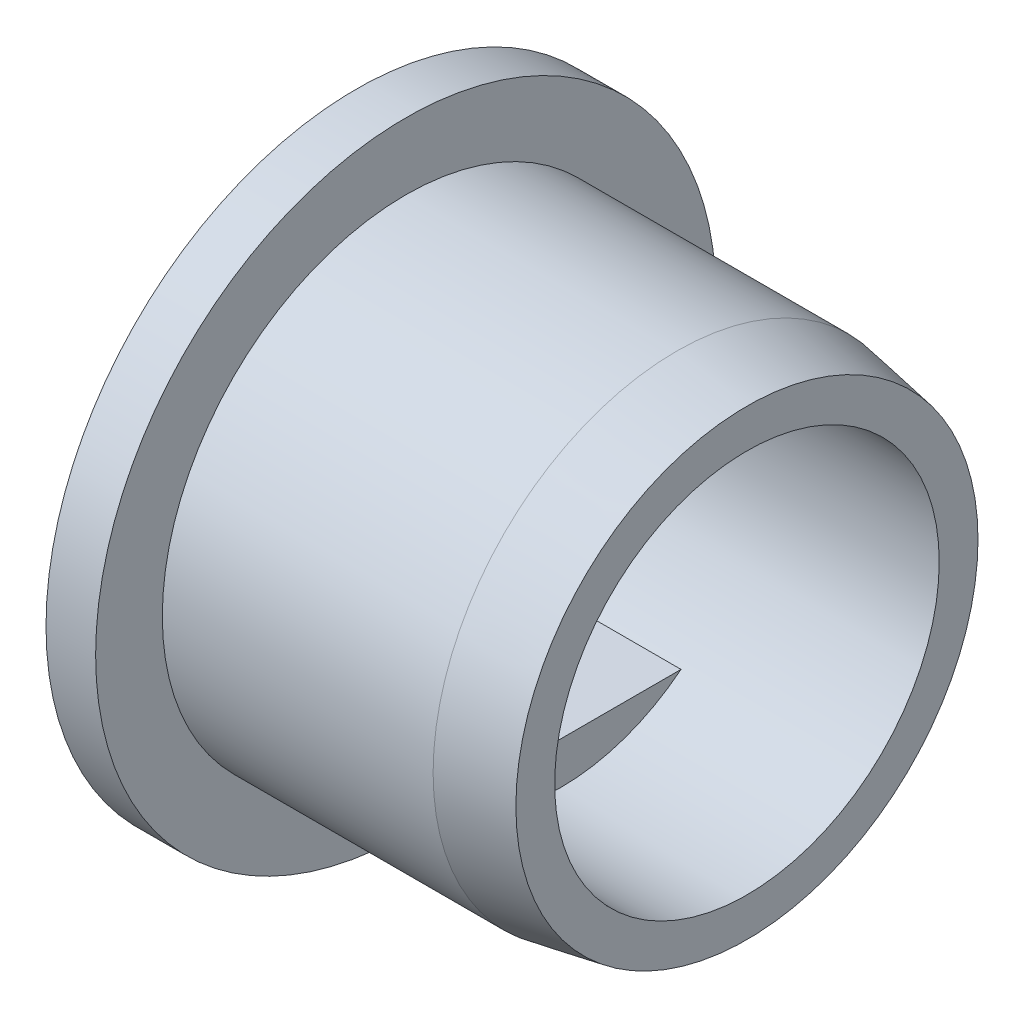
from build123d import *

# Parameters (mm, degrees)
SKETCH1_R                = 20
BOSS_EXTRUDE1_DEPTH      = 150
SKETCH1_3_R              = 8.5
BOSS_EXTRUDE2_DEPTH      = 0.8
BOSS_EXTRUDE3_START      = -0.8
SKETCH1_4_R              = 3.925
BOSS_EXTRUDE3_DEPTH      = 8.5
BOSS_EXTRUDE4_START      = 150
SKETCH1_9_R              = 8.5
SKETCH1_9_R_2            = 3.925
BOSS_EXTRUDE4_DEPTH      = 0.8
BOSS_EXTRUDE5_START      = 150.8
SKETCH1_10_R             = 3.925
BOSS_EXTRUDE5_DEPTH      = 5.5
SKETCH2_W                = 1
SKETCH2_H                = 2
SKETCH3_R                = 22.5
BOSS_EXTRUDE6_DEPTH      = 10
CUT_EXTRUDE1_START       = 156.3
CUT_EXTRUDE1_DEPTH       = 20
CUT_EXTRUDE2_START       = 156.3
CUT_EXTRUDE2_DEPTH       = 3
CUT_EXTRUDE3_DEPTH       = 10
FILLET1_R                = 0.5
FILLET2_R                = 1
CIRPATTERN1_COUNT        = 16
FILLET1_OF_CIRPATTERN1_R = 0.5
FILLET2_OF_CIRPATTERN1_R = 1
SKETCH4_OUTSIDE_W        = 82.236
SKETCH4_OUTSIDE_H        = 82.236
CUT_EXTRUDE4_DEPTH       = 10
CHAMFER1_SIZE            = 0.2
CHAMFER1_SIZE2           = 1.134256364
CHAMFER2_SIZE            = 0.2
CHAMFER2_SIZE2           = 1.134256364
SKETCH6_R                = 38.669160418
CUT_EXTRUDE5_DEPTH       = 160.3
SKETCH7_OUTSIDE_W        = 23.97
SKETCH7_OUTSIDE_H        = 23.97
SKETCH7_OUTSIDE_R        = 7
CUT_EXTRUDE6_DEPTH       = 10
SKETCH8_OUTSIDE_W        = 20.156
SKETCH8_OUTSIDE_H        = 20.156
SKETCH8_OUTSIDE_R        = 5
CUT_EXTRUDE7_DEPTH       = 10


with BuildPart() as part:
    # Sketch1 → Boss-Extrude1 (new body)
    with BuildSketch(Plane(origin=(0, 0, 0), x_dir=(0, 0, -1), z_dir=(1, 0, 0))):
        Circle(SKETCH1_R)
    extrude(amount=BOSS_EXTRUDE1_DEPTH)

    # Sketch1_3 → Boss-Extrude2 (add)
    with BuildSketch(Plane(origin=(0, 0, 0), x_dir=(0, 0, -1), z_dir=(1, 0, 0))):
        Circle(SKETCH1_3_R)
    extrude(amount=-BOSS_EXTRUDE2_DEPTH)

    # Sketch1_4 → Boss-Extrude3 (add)
    with BuildSketch(Plane(origin=(0, 0, 0), x_dir=(0, 0, -1), z_dir=(1, 0, 0)).offset(BOSS_EXTRUDE3_START)):
        Circle(SKETCH1_4_R)
    extrude(amount=-BOSS_EXTRUDE3_DEPTH)

    # Sketch1_9 → Boss-Extrude4 (add)
    with BuildSketch(Plane(origin=(0, 0, 0), x_dir=(0, 0, -1), z_dir=(1, 0, 0)).offset(BOSS_EXTRUDE4_START)):
        Circle(SKETCH1_9_R)
        Circle(SKETCH1_9_R_2, mode=Mode.SUBTRACT)
        Circle(SKETCH1_9_R_2)
        with BuildLine():
            ThreePointArc((1.937420966, -2.42), (0, 3.1), (-1.937420966, -2.42))
            ThreePointArc((-1.937420966, -2.42), (0, -3.1), (1.937420966, -2.42))
        make_face(mode=Mode.SUBTRACT)
        with BuildLine():
            Line((-1.937420966, -2.42), (1.937420966, -2.42))
            ThreePointArc((1.937420966, -2.42), (0, 3.1), (-1.937420966, -2.42))
        make_face()
        with BuildLine():
            ThreePointArc((1.937420966, -2.42), (0, -3.1), (-1.937420966, -2.42))
            Line((-1.937420966, -2.42), (1.937420966, -2.42))
        make_face()
    extrude(amount=BOSS_EXTRUDE4_DEPTH)

    # Sketch1_10 → Boss-Extrude5 (add)
    with BuildSketch(Plane(origin=(0, 0, 0), x_dir=(0, 0, -1), z_dir=(1, 0, 0)).offset(BOSS_EXTRUDE5_START)):
        Circle(SKETCH1_10_R)
    extrude(amount=BOSS_EXTRUDE5_DEPTH)

    # Sketch2 → Cut-Revolve1 (revolve, cut)
    with BuildSketch(Plane.XY, mode=Mode.PRIVATE) as cut_revolve1_sk:
        Polygon((27, 20), (1, 20), (1, 18), (14, 18.6), (27, 18), align=None)
        Polygon((27, 18), (27, 20), (28, 20), (29, 20), (29, 18), align=None)
        Polygon((29, 20), (29, 18), (42, 18.6), (55, 18), (55, 20), align=None)
        Polygon((55, 18), (55, 20), (56, 20), (57, 20), (57, 18), align=None)
        Polygon((57, 20), (57, 18), (70, 18.6), (83, 18), (83, 20), align=None)
        Polygon((83, 18), (83, 20), (84, 20), (85, 20), (85, 18), align=None)
        Polygon((85, 20), (85, 18), (98, 18.6), (111, 18), (111, 20), align=None)
        Polygon((111, 18), (111, 20), (112, 20), (113, 20), (113, 18), align=None)
        Polygon((113, 20), (113, 18), (126, 18.6), (139, 18), (139, 19.9), (139, 20), align=None)
        Polygon((140, 20), (139, 20), (139, 19.9), (150, 19.9), (150, 20), align=None)
        with Locations((0.5, 19)):
            Rectangle(SKETCH2_W, SKETCH2_H)
    revolve(cut_revolve1_sk.sketch.rotate(Axis((0, 0, 0), (1, 0, 0)), 90), axis=Axis((0, 0, 0), (1, 0, 0)), mode=Mode.SUBTRACT)  # turned: the seam where the file's is

    # Sketch3 → Boss-Extrude6 (add)
    with BuildSketch(Plane(origin=(150, 0, 0), x_dir=(0, 0, -1), z_dir=(1, 0, 0))):
        Circle(SKETCH3_R)
    extrude(amount=-BOSS_EXTRUDE6_DEPTH)

    # Sketch1_5 → Cut-Extrude1 (cut)
    with BuildSketch(Plane(origin=(0, 0, 0), x_dir=(0, 0, -1), z_dir=(1, 0, 0)).offset(CUT_EXTRUDE1_START)):
        with BuildLine():
            Line((-1.937420966, -2.42), (1.937420966, -2.42))
            ThreePointArc((1.937420966, -2.42), (0, 3.1), (-1.937420966, -2.42))
        make_face()
    extrude(amount=-CUT_EXTRUDE1_DEPTH, mode=Mode.SUBTRACT)

    # Sketch1_8 → Cut-Extrude2 (cut)
    with BuildSketch(Plane(origin=(0, 0, 0), x_dir=(0, 0, -1), z_dir=(1, 0, 0)).offset(CUT_EXTRUDE2_START)):
        with BuildLine():
            ThreePointArc((1.937420966, -2.42), (0, -3.1), (-1.937420966, -2.42))
            Line((-1.937420966, -2.42), (1.937420966, -2.42))
        make_face()
    extrude(amount=-CUT_EXTRUDE2_DEPTH, mode=Mode.SUBTRACT)

    # Sketch3_3 → Cut-Extrude3 (cut)
    with BuildSketch(Plane(origin=(150, 0, 0), x_dir=(0, 0, -1), z_dir=(1, 0, 0))):
        with BuildLine():
            Line((18.793852416, 0), (16.875, 0))
            ThreePointArc((16.875, 0), (16.816528534, -1.403564417), (16.641519339, -2.797402201))
            Line((16.641519339, -2.797402201), (18.533822722, -3.11549417))
            add(Edge.make_bspline(
                [(18.533822722, -3.11549417), (18.540143259, -3.116650367), (18.557818877, -3.120174741), (18.59102423, -3.127948355), (18.644868838, -3.14220254), (18.712949139, -3.162664487), (18.800284389, -3.191738795), (18.902266481, -3.229352045), (19.01333304, -3.274191401), (19.133012214, -3.326732031), (19.251334581, -3.382453012), (19.368317547, -3.441093179), (19.483872699, -3.502252085), (19.622639053, -3.579554465), (19.787320314, -3.676709438), (19.977176405, -3.796702318), (20.189293185, -3.940335966), (20.401861332, -4.094683446), (20.60799726, -4.25307101), (20.812611431, -4.420472139), (21.00798126, -4.587659246), (21.20695704, -4.768722867), (21.388624735, -4.939634627), (21.58456819, -5.136136858), (21.702177554, -5.256735347), (21.796059885, -5.357369907), (21.840902155, -5.406014525)],
                knots=[0, 0, 0, 0, 0, 0.005376749, 0.015083688, 0.02853182, 0.04661014, 0.064854849, 0.092110525, 0.119476176, 0.146842496, 0.174208854, 0.201574956, 0.228941013, 0.256307345, 0.307035032, 0.361767352, 0.416499661, 0.471231937, 0.525964282, 0.580696616, 0.635428982, 0.690161387, 0.744893688, 0.799626082, 0.851029126, 0.851029126, 0.851029126, 0.851029126, 0.851029126], degree=4))
            ThreePointArc((21.840902155, -5.406014525), (22.334617732, -2.723022357), (22.5, 0))
            ThreePointArc((22.5, 0), (22.483713995, 0.855923463), (22.434879558, 1.710607852))
            add(Edge.make_bspline(
                [(18.793852416, 0), (18.800277167, 9.2432e-05), (18.81829247, 0.000637921), (18.852327044, 0.002799463), (18.907789609, 0.007930502), (18.978319976, 0.016823532), (19.06926657, 0.031017834), (19.176072873, 0.051204897), (19.293035835, 0.077012138), (19.419768906, 0.108986367), (19.545691155, 0.144321865), (19.670776454, 0.182758195), (19.79487123, 0.223915106), (19.944532197, 0.277144366), (20.123040519, 0.345655574), (20.33016124, 0.432515425), (20.563153629, 0.538998755), (20.798367194, 0.655972857), (21.027907269, 0.777997426), (21.257440837, 0.909163115), (21.477822489, 1.041650195), (21.704060536, 1.187224031), (21.911547079, 1.32565566), (22.137354045, 1.486957173), (22.27332803, 1.586390737), (22.382593806, 1.670069867), (22.434879558, 1.710607852)],
                knots=[0, 0, 0, 0, 0, 0.005376749, 0.015083688, 0.02853182, 0.04661014, 0.064854849, 0.092110525, 0.119476176, 0.146842496, 0.174208854, 0.201574956, 0.228941013, 0.256307345, 0.307035032, 0.361767352, 0.416499661, 0.471231937, 0.525964282, 0.580696616, 0.635428982, 0.690161387, 0.744893688, 0.799626082, 0.851029126, 0.851029126, 0.851029126, 0.851029126, 0.851029126], degree=4))
        make_face()
        with BuildLine():
            Line((18.793852416, 0), (16.875, 0))
            ThreePointArc((16.875, 0), (16.816528534, -1.403564417), (16.641519339, -2.797402201))
            Line((16.641519339, -2.797402201), (18.533822722, -3.11549417))
            add(Edge.make_bspline(
                [(18.533822722, -3.11549417), (18.540143259, -3.116650367), (18.557818877, -3.120174741), (18.59102423, -3.127948355), (18.644868838, -3.14220254), (18.712949139, -3.162664487), (18.800284389, -3.191738795), (18.902266481, -3.229352045), (19.01333304, -3.274191401), (19.133012214, -3.326732031), (19.251334581, -3.382453012), (19.368317547, -3.441093179), (19.483872699, -3.502252085), (19.622639053, -3.579554465), (19.787320314, -3.676709438), (19.977176405, -3.796702318), (20.189293185, -3.940335966), (20.401861332, -4.094683446), (20.60799726, -4.25307101), (20.812611431, -4.420472139), (21.00798126, -4.587659246), (21.20695704, -4.768722867), (21.388624735, -4.939634627), (21.58456819, -5.136136858), (21.702177554, -5.256735347), (21.796059885, -5.357369907), (21.840902155, -5.406014525)],
                knots=[0, 0, 0, 0, 0, 0.005376749, 0.015083688, 0.02853182, 0.04661014, 0.064854849, 0.092110525, 0.119476176, 0.146842496, 0.174208854, 0.201574956, 0.228941013, 0.256307345, 0.307035032, 0.361767352, 0.416499661, 0.471231937, 0.525964282, 0.580696616, 0.635428982, 0.690161387, 0.744893688, 0.799626082, 0.851029126, 0.851029126, 0.851029126, 0.851029126, 0.851029126], degree=4))
            ThreePointArc((21.840902155, -5.406014525), (22.334617732, -2.723022357), (22.5, 0))
            ThreePointArc((22.5, 0), (22.483713995, 0.855923463), (22.434879558, 1.710607852))
            add(Edge.make_bspline(
                [(18.793852416, 0), (18.800277167, 9.2432e-05), (18.81829247, 0.000637921), (18.852327044, 0.002799463), (18.907789609, 0.007930502), (18.978319976, 0.016823532), (19.06926657, 0.031017834), (19.176072873, 0.051204897), (19.293035835, 0.077012138), (19.419768906, 0.108986367), (19.545691155, 0.144321865), (19.670776454, 0.182758195), (19.79487123, 0.223915106), (19.944532197, 0.277144366), (20.123040519, 0.345655574), (20.33016124, 0.432515425), (20.563153629, 0.538998755), (20.798367194, 0.655972857), (21.027907269, 0.777997426), (21.257440837, 0.909163115), (21.477822489, 1.041650195), (21.704060536, 1.187224031), (21.911547079, 1.32565566), (22.137354045, 1.486957173), (22.27332803, 1.586390737), (22.382593806, 1.670069867), (22.434879558, 1.710607852)],
                knots=[0, 0, 0, 0, 0, 0.005376749, 0.015083688, 0.02853182, 0.04661014, 0.064854849, 0.092110525, 0.119476176, 0.146842496, 0.174208854, 0.201574956, 0.228941013, 0.256307345, 0.307035032, 0.361767352, 0.416499661, 0.471231937, 0.525964282, 0.580696616, 0.635428982, 0.690161387, 0.744893688, 0.799626082, 0.851029126, 0.851029126, 0.851029126, 0.851029126, 0.851029126], degree=4))
        make_face()
    cut_extrude3 = extrude(amount=-CUT_EXTRUDE3_DEPTH, mode=Mode.SUBTRACT)

    # Fillet1
    fillet1_edges = [part.edges().sort_by_distance(p)[0] for p in [
        (145, -2.797402201, -16.641519339),
        (145, 0, -16.875),
    ]]
    fillet(fillet1_edges, radius=FILLET1_R)

    # Fillet2
    fillet2_edges = [part.edges().sort_by_distance(p)[0] for p in [
        (145, 1.710607852, -22.434879558),
        (145, -5.406014525, -21.840902155),
    ]]
    fillet(fillet2_edges, radius=FILLET2_R)

    # CirPattern1: Cut-Extrude3 ×16 about axis
    cirpattern1_axis = Axis((126, 0, 0), (-1, 0, 0))
    for i in range(1, CIRPATTERN1_COUNT):
        add(cut_extrude3.rotate(cirpattern1_axis, i * 360 / CIRPATTERN1_COUNT), mode=Mode.SUBTRACT)

    # Fillet1 of CirPattern1
    fillet1_of_cirpattern1_edges = [part.edges().sort_by_distance(p)[0] for p in [
        (145, -8.952896379, -14.304239631),
        (145, -6.457782921, -15.590467111),
        (145, -13.74539324, -9.789269108),
        (145, -11.932426933, -11.932426933),
        (145, -16.445278584, -3.783971103),
        (145, -15.590467111, -6.457782921),
        (145, -16.641519339, 2.797402201),
        (145, -16.875, 0),
        (145, -14.304239631, 8.952896379),
        (145, -15.590467111, 6.457782921),
        (145, -9.789269108, 13.74539324),
        (145, -11.932426933, 11.932426933),
        (145, -3.783971103, 16.445278584),
        (145, -6.457782921, 15.590467111),
        (145, 2.797402201, 16.641519339),
        (145, 0, 16.875),
        (145, 8.952896379, 14.304239631),
        (145, 6.457782921, 15.590467111),
        (145, 13.74539324, 9.789269108),
        (145, 11.932426933, 11.932426933),
        (145, 16.445278584, 3.783971103),
        (145, 15.590467111, 6.457782921),
        (145, 16.641519339, -2.797402201),
        (145, 16.875, 0),
        (145, 14.304239631, -8.952896379),
        (145, 15.590467111, -6.457782921),
        (145, 9.789269108, -13.74539324),
        (145, 11.932426933, -11.932426933),
        (145, 3.783971103, -16.445278584),
        (145, 6.457782921, -15.590467111),
    ]]
    fillet(fillet1_of_cirpattern1_edges, radius=FILLET1_OF_CIRPATTERN1_R)

    # Fillet2 of CirPattern1
    fillet2_of_cirpattern1_edges = [part.edges().sort_by_distance(p)[0] for p in [
        (145, -7.005061131, -21.381747322),
        (145, -13.352657575, -18.109570279),
        (145, -14.654273058, -17.073437883),
        (145, -19.266479551, -11.621220491),
        (145, -20.072504754, -10.165852297),
        (145, -22.247154667, -3.36364523),
        (145, -22.434879558, -1.710607852),
        (145, -21.840902155, 5.406014525),
        (145, -21.381747322, 7.005061131),
        (145, -18.109570279, 13.352657575),
        (145, -17.073437883, 14.654273058),
        (145, -11.621220491, 19.266479551),
        (145, -10.165852297, 20.072504754),
        (145, -3.36364523, 22.247154667),
        (145, -1.710607852, 22.434879558),
        (145, 5.406014525, 21.840902155),
        (145, 7.005061131, 21.381747322),
        (145, 13.352657575, 18.109570279),
        (145, 14.654273058, 17.073437883),
        (145, 19.266479551, 11.621220491),
        (145, 20.072504754, 10.165852297),
        (145, 22.247154667, 3.36364523),
        (145, 22.434879558, 1.710607852),
        (145, 21.840902155, -5.406014525),
        (145, 21.381747322, -7.005061131),
        (145, 18.109570279, -13.352657575),
        (145, 17.073437883, -14.654273058),
        (145, 11.621220491, -19.266479551),
        (145, 10.165852297, -20.072504754),
        (145, 3.36364523, -22.247154667),
    ]]
    fillet(fillet2_of_cirpattern1_edges, radius=FILLET2_OF_CIRPATTERN1_R)

    # Sketch4 outside → Cut-Extrude4 (cut)
    with BuildSketch(Plane(origin=(150, 0, 0), x_dir=(0, 0, -1), z_dir=(1, 0, 0))):
        Rectangle(SKETCH4_OUTSIDE_W, SKETCH4_OUTSIDE_H)
        with BuildLine():
            Line((16.084027229, -6.553982996), (17.400825548, -7.099418718))
            add(Edge.make_bspline(
                [(17.400825548, -7.099418718), (17.468205114, -7.126079363), (17.53735939, -7.143460734), (17.675930951, -7.176848305), (17.745707701, -7.190975003), (17.956070336, -7.22795715), (18.097788211, -7.245382593), (18.52533898, -7.282064664), (18.810706139, -7.285520422), (19.667508071, -7.251758438), (20.232380272, -7.171231176), (20.790500392, -7.047676668)],
                knots=[0, 0, 0, 0, 0.0625, 0.0625, 0.125, 0.125, 0.25, 0.25, 0.5, 0.5, 1, 1, 1, 1], degree=3))
            ThreePointArc((20.790500392, -7.047676668), (21.208669056, -6.828194438), (21.458128433, -6.427186333))
            ThreePointArc((21.458128433, -6.427186333), (21.529993052, -6.182184014), (21.599060408, -5.936378481))
            ThreePointArc((21.599060408, -5.936378481), (21.600355656, -5.464111816), (21.362335917, -5.056209764))
            add(Edge.make_bspline(
                [(21.362335917, -5.056209764), (20.954562332, -4.655146223), (20.516130086, -4.285439291), (19.808296094, -3.802964384), (19.563276919, -3.653961081), (19.184028171, -3.459717512), (19.055472444, -3.399677951), (18.858095781, -3.31961644), (18.79155061, -3.294586267), (18.656290761, -3.249300304), (18.588391332, -3.227250414), (18.516500063, -3.213985271)],
                knots=[0, 0, 0, 0, 0.5, 0.5, 0.75, 0.75, 0.875, 0.875, 0.9375, 0.9375, 1, 1, 1, 1], degree=3))
            Line((18.516500063, -3.213985271), (17.11092802, -2.977711752))
            ThreePointArc((17.11092802, -2.977711752), (16.726725338, -2.741072894), (16.616075542, -2.303618583))
            ThreePointArc((16.616075542, -2.303618583), (16.716875031, -1.395246999), (16.768052751, -0.482733813))
            ThreePointArc((16.768052751, -0.482733813), (16.949689277, -0.069674709), (17.367804265, 0.1))
            Line((17.367804265, 0.1), (18.793096495, 0.1))
            add(Edge.make_bspline(
                [(18.793096495, 0.1), (18.865549684, 0.10115382), (18.936091467, 0.111559723), (19.076891767, 0.13374267), (19.146763131, 0.147393709), (19.355265319, 0.193728955), (19.492863991, 0.231863028), (19.901907017, 0.361589809), (20.166874355, 0.467602389), (20.945535972, 0.826678299), (21.436593388, 1.117243022), (21.904946881, 1.444975825)],
                knots=[0, 0, 0, 0, 0.0625, 0.0625, 0.125, 0.125, 0.25, 0.25, 0.5, 0.5, 1, 1, 1, 1], degree=3))
            ThreePointArc((21.904946881, 1.444975825), (22.207292137, 1.807777185), (22.284303392, 2.273724336))
            ThreePointArc((22.284303392, 2.273724336), (22.256939314, 2.527578363), (22.226683526, 2.781103997))
            ThreePointArc((22.226683526, 2.781103997), (22.04715155, 3.217917173), (21.671152627, 3.503683319))
            add(Edge.make_bspline(
                [(21.671152627, 3.503683319), (21.140938586, 3.718169521), (20.59439929, 3.891953432), (19.755810799, 4.066825781), (19.472421503, 4.110722104), (19.047707551, 4.145047549), (18.905961401, 4.151320724), (18.692970927, 4.149755137), (18.621912574, 4.147414267), (18.47961858, 4.137491338), (18.40844956, 4.131878793), (18.336954337, 4.11662259)],
                knots=[0, 0, 0, 0, 0.5, 0.5, 0.75, 0.75, 0.875, 0.875, 0.9375, 0.9375, 1, 1, 1, 1], degree=3))
            Line((18.336954337, 4.11662259), (16.947957134, 3.797021724))
            ThreePointArc((16.947957134, 3.797021724), (16.502442369, 3.868619521), (16.23280877, 4.230430761))
            ThreePointArc((16.23280877, 4.230430761), (15.978316599, 5.108230971), (15.676394969, 5.970868091))
            ThreePointArc((15.676394969, 5.970868091), (15.686134362, 6.421994232), (16.007490542, 6.738758902))
            Line((16.007490542, 6.738758902), (17.324288861, 7.284194625))
            add(Edge.make_bspline(
                [(17.324288861, 7.284194625), (17.390785332, 7.31298725), (17.451975275, 7.349596223), (17.573568743, 7.423972535), (17.63289744, 7.463323064), (17.807796613, 7.585921583), (17.920327932, 7.673809605), (18.248590122, 7.950195511), (18.452818764, 8.149536975), (19.034795893, 8.779260759), (19.377279484, 9.235627096), (19.684563776, 9.717643848)],
                knots=[0, 0, 0, 0, 0.0625, 0.0625, 0.125, 0.125, 0.25, 0.25, 0.5, 0.5, 1, 1, 1, 1], degree=3))
            ThreePointArc((19.684563776, 9.717643848), (19.8250563, 10.168531119), (19.717895167, 10.628481086))
            ThreePointArc((19.717895167, 10.628481086), (19.595468325, 10.852539847), (19.470495562, 11.075188602))
            ThreePointArc((19.470495562, 11.075188602), (19.137468479, 11.410047442), (18.6807328, 11.530172378))
            add(Edge.make_bspline(
                [(18.6807328, 11.530172378), (18.108798583, 11.525427661), (17.537357891, 11.476831525), (16.695682397, 11.317478587), (16.41706643, 11.249585113), (16.011546124, 11.118766696), (15.878189117, 11.070318451), (15.682010702, 10.987364112), (15.617257156, 10.958008575), (15.489591988, 10.89438743), (15.425988215, 10.86196691), (15.365773538, 10.820511979)],
                knots=[0, 0, 0, 0, 0.5, 0.5, 0.75, 0.75, 0.875, 0.875, 0.9375, 0.9375, 1, 1, 1, 1], degree=3))
            Line((15.365773538, 10.820511979), (14.204813408, 9.993693063))
            ThreePointArc((14.204813408, 9.993693063), (13.765812144, 9.889349683), (13.378244014, 10.120435371))
            ThreePointArc((13.378244014, 10.120435371), (12.807204309, 10.834027081), (12.19814816, 11.515459455))
            ThreePointArc((12.19814816, 11.515459455), (12.034507686, 11.935972767), (12.210181492, 12.351602848))
            Line((12.210181492, 12.351602848), (13.218015293, 13.35943665))
            add(Edge.make_bspline(
                [(13.218015293, 13.35943665), (13.26843156, 13.411484664), (13.310954049, 13.468723322), (13.394829183, 13.583969881), (13.434582957, 13.643029139), (13.549252301, 13.823226417), (13.619584394, 13.947488232), (13.817090804, 14.328456016), (13.929488792, 14.590778432), (14.22618069, 15.395280352), (14.367950434, 15.947970667), (14.467384276, 16.510888685)],
                knots=[0, 0, 0, 0, 0.0625, 0.0625, 0.125, 0.125, 0.25, 0.25, 0.5, 0.5, 1, 1, 1, 1], degree=3))
            ThreePointArc((14.467384276, 16.510888685), (14.424635355, 16.981218368), (14.149616146, 17.365147939))
            ThreePointArc((14.149616146, 17.365147939), (13.950764917, 17.525300518), (13.750101149, 17.68317614))
            ThreePointArc((13.750101149, 17.68317614), (13.314279313, 17.865101421), (12.846340745, 17.801297213))
            add(Edge.make_bspline(
                [(12.846340745, 17.801297213), (12.319758153, 17.578043917), (11.810412729, 17.314466056), (11.093787696, 16.845147872), (10.862361815, 16.675800766), (10.537771945, 16.399754405), (10.433106477, 16.303960546), (10.283606506, 16.152246501), (10.235015907, 16.100345412), (10.141415429, 15.992711794), (10.095060001, 15.938419029), (10.055293009, 15.877076507)],
                knots=[0, 0, 0, 0, 0.5, 0.5, 0.75, 0.75, 0.875, 0.875, 0.9375, 0.9375, 1, 1, 1, 1], degree=3))
            Line((10.055293009, 15.877076507), (9.299115607, 14.668915226))
            ThreePointArc((9.299115607, 14.668915226), (8.933461808, 14.404516002), (8.486962881, 14.469695438))
            ThreePointArc((8.486962881, 14.469695438), (7.68631126, 14.910440779), (6.86284387, 15.306926504))
            ThreePointArc((6.86284387, 15.306926504), (6.550736307, 15.632807648), (6.553982996, 16.084027229))
            Line((6.553982996, 16.084027229), (7.099418718, 17.400825548))
            add(Edge.make_bspline(
                [(7.099418718, 17.400825548), (7.126079363, 17.468205114), (7.143460734, 17.53735939), (7.176848305, 17.675930951), (7.190975003, 17.745707701), (7.22795715, 17.956070336), (7.245382593, 18.097788211), (7.282064664, 18.52533898), (7.285520422, 18.810706139), (7.251758438, 19.667508071), (7.171231176, 20.232380272), (7.047676668, 20.790500392)],
                knots=[0, 0, 0, 0, 0.0625, 0.0625, 0.125, 0.125, 0.25, 0.25, 0.5, 0.5, 1, 1, 1, 1], degree=3))
            ThreePointArc((7.047676668, 20.790500392), (6.828194438, 21.208669056), (6.427186333, 21.458128433))
            ThreePointArc((6.427186333, 21.458128433), (6.182184014, 21.529993052), (5.936378481, 21.599060408))
            ThreePointArc((5.936378481, 21.599060408), (5.464111816, 21.600355656), (5.056209764, 21.362335917))
            add(Edge.make_bspline(
                [(5.056209764, 21.362335917), (4.655146223, 20.954562332), (4.285439291, 20.516130086), (3.802964384, 19.808296094), (3.653961081, 19.563276919), (3.459717512, 19.184028171), (3.399677951, 19.055472444), (3.31961644, 18.858095781), (3.294586267, 18.79155061), (3.249300304, 18.656290761), (3.227250414, 18.588391332), (3.213985271, 18.516500063)],
                knots=[0, 0, 0, 0, 0.5, 0.5, 0.75, 0.75, 0.875, 0.875, 0.9375, 0.9375, 1, 1, 1, 1], degree=3))
            Line((3.213985271, 18.516500063), (2.977711752, 17.11092802))
            ThreePointArc((2.977711752, 17.11092802), (2.741072894, 16.726725338), (2.303618583, 16.616075542))
            ThreePointArc((2.303618583, 16.616075542), (1.395246999, 16.716875031), (0.482733813, 16.768052751))
            ThreePointArc((0.482733813, 16.768052751), (0.069674709, 16.949689277), (-0.1, 17.367804265))
            Line((-0.1, 17.367804265), (-0.1, 18.793096495))
            add(Edge.make_bspline(
                [(-0.1, 18.793096495), (-0.10115382, 18.865549684), (-0.111559723, 18.936091467), (-0.13374267, 19.076891767), (-0.147393709, 19.146763131), (-0.193728955, 19.355265319), (-0.231863028, 19.492863991), (-0.361589809, 19.901907017), (-0.467602389, 20.166874355), (-0.826678299, 20.945535972), (-1.117243022, 21.436593388), (-1.444975825, 21.904946881)],
                knots=[0, 0, 0, 0, 0.0625, 0.0625, 0.125, 0.125, 0.25, 0.25, 0.5, 0.5, 1, 1, 1, 1], degree=3))
            ThreePointArc((-1.444975825, 21.904946881), (-1.807777185, 22.207292137), (-2.273724336, 22.284303392))
            ThreePointArc((-2.273724336, 22.284303392), (-2.527578363, 22.256939314), (-2.781103997, 22.226683526))
            ThreePointArc((-2.781103997, 22.226683526), (-3.217917173, 22.04715155), (-3.503683319, 21.671152627))
            add(Edge.make_bspline(
                [(-3.503683319, 21.671152627), (-3.718169521, 21.140938586), (-3.891953432, 20.59439929), (-4.066825781, 19.755810799), (-4.110722104, 19.472421503), (-4.145047549, 19.047707551), (-4.151320724, 18.905961401), (-4.149755137, 18.692970927), (-4.147414267, 18.621912574), (-4.137491338, 18.47961858), (-4.131878793, 18.40844956), (-4.11662259, 18.336954337)],
                knots=[0, 0, 0, 0, 0.5, 0.5, 0.75, 0.75, 0.875, 0.875, 0.9375, 0.9375, 1, 1, 1, 1], degree=3))
            Line((-4.11662259, 18.336954337), (-3.797021724, 16.947957134))
            ThreePointArc((-3.797021724, 16.947957134), (-3.868619521, 16.502442369), (-4.230430761, 16.23280877))
            ThreePointArc((-4.230430761, 16.23280877), (-5.108230971, 15.978316599), (-5.970868091, 15.676394969))
            ThreePointArc((-5.970868091, 15.676394969), (-6.421994232, 15.686134362), (-6.738758902, 16.007490542))
            Line((-6.738758902, 16.007490542), (-7.284194625, 17.324288861))
            add(Edge.make_bspline(
                [(-7.284194625, 17.324288861), (-7.31298725, 17.390785332), (-7.349596223, 17.451975275), (-7.423972535, 17.573568743), (-7.463323064, 17.63289744), (-7.585921583, 17.807796613), (-7.673809605, 17.920327932), (-7.950195511, 18.248590122), (-8.149536975, 18.452818764), (-8.779260759, 19.034795893), (-9.235627096, 19.377279484), (-9.717643848, 19.684563776)],
                knots=[0, 0, 0, 0, 0.0625, 0.0625, 0.125, 0.125, 0.25, 0.25, 0.5, 0.5, 1, 1, 1, 1], degree=3))
            ThreePointArc((-9.717643848, 19.684563776), (-10.168531119, 19.8250563), (-10.628481086, 19.717895167))
            ThreePointArc((-10.628481086, 19.717895167), (-10.852539847, 19.595468325), (-11.075188602, 19.470495562))
            ThreePointArc((-11.075188602, 19.470495562), (-11.410047442, 19.137468479), (-11.530172378, 18.6807328))
            add(Edge.make_bspline(
                [(-11.530172378, 18.6807328), (-11.525427661, 18.108798583), (-11.476831525, 17.537357891), (-11.317478587, 16.695682397), (-11.249585113, 16.41706643), (-11.118766696, 16.011546124), (-11.070318451, 15.878189117), (-10.987364112, 15.682010702), (-10.958008575, 15.617257156), (-10.89438743, 15.489591988), (-10.86196691, 15.425988215), (-10.820511979, 15.365773538)],
                knots=[0, 0, 0, 0, 0.5, 0.5, 0.75, 0.75, 0.875, 0.875, 0.9375, 0.9375, 1, 1, 1, 1], degree=3))
            Line((-10.820511979, 15.365773538), (-9.993693063, 14.204813408))
            ThreePointArc((-9.993693063, 14.204813408), (-9.889349683, 13.765812144), (-10.120435371, 13.378244014))
            ThreePointArc((-10.120435371, 13.378244014), (-10.834027081, 12.807204309), (-11.515459455, 12.19814816))
            ThreePointArc((-11.515459455, 12.19814816), (-11.935972767, 12.034507686), (-12.351602848, 12.210181492))
            Line((-12.351602848, 12.210181492), (-13.35943665, 13.218015293))
            add(Edge.make_bspline(
                [(-13.35943665, 13.218015293), (-13.411484664, 13.26843156), (-13.468723322, 13.310954049), (-13.583969881, 13.394829183), (-13.643029139, 13.434582957), (-13.823226417, 13.549252301), (-13.947488232, 13.619584394), (-14.328456016, 13.817090804), (-14.590778432, 13.929488792), (-15.395280352, 14.22618069), (-15.947970667, 14.367950434), (-16.510888685, 14.467384276)],
                knots=[0, 0, 0, 0, 0.0625, 0.0625, 0.125, 0.125, 0.25, 0.25, 0.5, 0.5, 1, 1, 1, 1], degree=3))
            ThreePointArc((-16.510888685, 14.467384276), (-16.981218368, 14.424635355), (-17.365147939, 14.149616146))
            ThreePointArc((-17.365147939, 14.149616146), (-17.525300518, 13.950764917), (-17.68317614, 13.750101149))
            ThreePointArc((-17.68317614, 13.750101149), (-17.865101421, 13.314279313), (-17.801297213, 12.846340745))
            add(Edge.make_bspline(
                [(-17.801297213, 12.846340745), (-17.578043917, 12.319758153), (-17.314466056, 11.810412729), (-16.845147872, 11.093787696), (-16.675800766, 10.862361815), (-16.399754405, 10.537771945), (-16.303960546, 10.433106477), (-16.152246501, 10.283606506), (-16.100345412, 10.235015907), (-15.992711794, 10.141415429), (-15.938419029, 10.095060001), (-15.877076507, 10.055293009)],
                knots=[0, 0, 0, 0, 0.5, 0.5, 0.75, 0.75, 0.875, 0.875, 0.9375, 0.9375, 1, 1, 1, 1], degree=3))
            Line((-15.877076507, 10.055293009), (-14.668915226, 9.299115607))
            ThreePointArc((-14.668915226, 9.299115607), (-14.404516002, 8.933461808), (-14.469695438, 8.486962881))
            ThreePointArc((-14.469695438, 8.486962881), (-14.910440779, 7.68631126), (-15.306926504, 6.86284387))
            ThreePointArc((-15.306926504, 6.86284387), (-15.632807648, 6.550736307), (-16.084027229, 6.553982996))
            Line((-16.084027229, 6.553982996), (-17.400825548, 7.099418718))
            add(Edge.make_bspline(
                [(-17.400825548, 7.099418718), (-17.468205114, 7.126079363), (-17.53735939, 7.143460734), (-17.675930951, 7.176848305), (-17.745707701, 7.190975003), (-17.956070336, 7.22795715), (-18.097788211, 7.245382593), (-18.52533898, 7.282064664), (-18.810706139, 7.285520422), (-19.667508071, 7.251758438), (-20.232380272, 7.171231176), (-20.790500392, 7.047676668)],
                knots=[0, 0, 0, 0, 0.0625, 0.0625, 0.125, 0.125, 0.25, 0.25, 0.5, 0.5, 1, 1, 1, 1], degree=3))
            ThreePointArc((-20.790500392, 7.047676668), (-21.208669056, 6.828194438), (-21.458128433, 6.427186333))
            ThreePointArc((-21.458128433, 6.427186333), (-21.529993052, 6.182184014), (-21.599060408, 5.936378481))
            ThreePointArc((-21.599060408, 5.936378481), (-21.600355656, 5.464111816), (-21.362335917, 5.056209764))
            add(Edge.make_bspline(
                [(-21.362335917, 5.056209764), (-20.954562332, 4.655146223), (-20.516130086, 4.285439291), (-19.808296094, 3.802964384), (-19.563276919, 3.653961081), (-19.184028171, 3.459717512), (-19.055472444, 3.399677951), (-18.858095781, 3.31961644), (-18.79155061, 3.294586267), (-18.656290761, 3.249300304), (-18.588391332, 3.227250414), (-18.516500063, 3.213985271)],
                knots=[0, 0, 0, 0, 0.5, 0.5, 0.75, 0.75, 0.875, 0.875, 0.9375, 0.9375, 1, 1, 1, 1], degree=3))
            Line((-18.516500063, 3.213985271), (-17.11092802, 2.977711752))
            ThreePointArc((-17.11092802, 2.977711752), (-16.726725338, 2.741072894), (-16.616075542, 2.303618583))
            ThreePointArc((-16.616075542, 2.303618583), (-16.716875031, 1.395246999), (-16.768052751, 0.482733813))
            ThreePointArc((-16.768052751, 0.482733813), (-16.949689277, 0.069674709), (-17.367804265, -0.1))
            Line((-17.367804265, -0.1), (-18.793096495, -0.1))
            add(Edge.make_bspline(
                [(-18.793096495, -0.1), (-18.865549684, -0.10115382), (-18.936091467, -0.111559723), (-19.076891767, -0.13374267), (-19.146763131, -0.147393709), (-19.355265319, -0.193728955), (-19.492863991, -0.231863028), (-19.901907017, -0.361589809), (-20.166874355, -0.467602389), (-20.945535972, -0.826678299), (-21.436593388, -1.117243022), (-21.904946881, -1.444975825)],
                knots=[0, 0, 0, 0, 0.0625, 0.0625, 0.125, 0.125, 0.25, 0.25, 0.5, 0.5, 1, 1, 1, 1], degree=3))
            ThreePointArc((-21.904946881, -1.444975825), (-22.207292137, -1.807777185), (-22.284303392, -2.273724336))
            ThreePointArc((-22.284303392, -2.273724336), (-22.256939314, -2.527578363), (-22.226683526, -2.781103997))
            ThreePointArc((-22.226683526, -2.781103997), (-22.04715155, -3.217917173), (-21.671152627, -3.503683319))
            add(Edge.make_bspline(
                [(-21.671152627, -3.503683319), (-21.140938586, -3.718169521), (-20.59439929, -3.891953432), (-19.755810799, -4.066825781), (-19.472421503, -4.110722104), (-19.047707551, -4.145047549), (-18.905961401, -4.151320724), (-18.692970927, -4.149755137), (-18.621912574, -4.147414267), (-18.47961858, -4.137491338), (-18.40844956, -4.131878793), (-18.336954337, -4.11662259)],
                knots=[0, 0, 0, 0, 0.5, 0.5, 0.75, 0.75, 0.875, 0.875, 0.9375, 0.9375, 1, 1, 1, 1], degree=3))
            Line((-18.336954337, -4.11662259), (-16.947957134, -3.797021724))
            ThreePointArc((-16.947957134, -3.797021724), (-16.502442369, -3.868619521), (-16.23280877, -4.230430761))
            ThreePointArc((-16.23280877, -4.230430761), (-15.978316599, -5.108230971), (-15.676394969, -5.970868091))
            ThreePointArc((-15.676394969, -5.970868091), (-15.686134362, -6.421994232), (-16.007490542, -6.738758902))
            Line((-16.007490542, -6.738758902), (-17.324288861, -7.284194625))
            add(Edge.make_bspline(
                [(-17.324288861, -7.284194625), (-17.390785332, -7.31298725), (-17.451975275, -7.349596223), (-17.573568743, -7.423972535), (-17.63289744, -7.463323064), (-17.807796613, -7.585921583), (-17.920327932, -7.673809605), (-18.248590122, -7.950195511), (-18.452818764, -8.149536975), (-19.034795893, -8.779260759), (-19.377279484, -9.235627096), (-19.684563776, -9.717643848)],
                knots=[0, 0, 0, 0, 0.0625, 0.0625, 0.125, 0.125, 0.25, 0.25, 0.5, 0.5, 1, 1, 1, 1], degree=3))
            ThreePointArc((-19.684563776, -9.717643848), (-19.8250563, -10.168531119), (-19.717895167, -10.628481086))
            ThreePointArc((-19.717895167, -10.628481086), (-19.595468325, -10.852539847), (-19.470495562, -11.075188602))
            ThreePointArc((-19.470495562, -11.075188602), (-19.137468479, -11.410047442), (-18.6807328, -11.530172378))
            add(Edge.make_bspline(
                [(-18.6807328, -11.530172378), (-18.108798583, -11.525427661), (-17.537357891, -11.476831525), (-16.695682397, -11.317478587), (-16.41706643, -11.249585113), (-16.011546124, -11.118766696), (-15.878189117, -11.070318451), (-15.682010702, -10.987364112), (-15.617257156, -10.958008575), (-15.489591988, -10.89438743), (-15.425988215, -10.86196691), (-15.365773538, -10.820511979)],
                knots=[0, 0, 0, 0, 0.5, 0.5, 0.75, 0.75, 0.875, 0.875, 0.9375, 0.9375, 1, 1, 1, 1], degree=3))
            Line((-15.365773538, -10.820511979), (-14.204813408, -9.993693063))
            ThreePointArc((-14.204813408, -9.993693063), (-13.765812144, -9.889349683), (-13.378244014, -10.120435371))
            ThreePointArc((-13.378244014, -10.120435371), (-12.807204309, -10.834027081), (-12.19814816, -11.515459455))
            ThreePointArc((-12.19814816, -11.515459455), (-12.034507686, -11.935972767), (-12.210181492, -12.351602848))
            Line((-12.210181492, -12.351602848), (-13.218015293, -13.35943665))
            add(Edge.make_bspline(
                [(-13.218015293, -13.35943665), (-13.26843156, -13.411484664), (-13.310954049, -13.468723322), (-13.394829183, -13.583969881), (-13.434582957, -13.643029139), (-13.549252301, -13.823226417), (-13.619584394, -13.947488232), (-13.817090804, -14.328456016), (-13.929488792, -14.590778432), (-14.22618069, -15.395280352), (-14.367950434, -15.947970667), (-14.467384276, -16.510888685)],
                knots=[0, 0, 0, 0, 0.0625, 0.0625, 0.125, 0.125, 0.25, 0.25, 0.5, 0.5, 1, 1, 1, 1], degree=3))
            ThreePointArc((-14.467384276, -16.510888685), (-14.424635355, -16.981218368), (-14.149616146, -17.365147939))
            ThreePointArc((-14.149616146, -17.365147939), (-13.950764917, -17.525300518), (-13.750101149, -17.68317614))
            ThreePointArc((-13.750101149, -17.68317614), (-13.314279313, -17.865101421), (-12.846340745, -17.801297213))
            add(Edge.make_bspline(
                [(-12.846340745, -17.801297213), (-12.319758153, -17.578043917), (-11.810412729, -17.314466056), (-11.093787696, -16.845147872), (-10.862361815, -16.675800766), (-10.537771945, -16.399754405), (-10.433106477, -16.303960546), (-10.283606506, -16.152246501), (-10.235015907, -16.100345412), (-10.141415429, -15.992711794), (-10.095060001, -15.938419029), (-10.055293009, -15.877076507)],
                knots=[0, 0, 0, 0, 0.5, 0.5, 0.75, 0.75, 0.875, 0.875, 0.9375, 0.9375, 1, 1, 1, 1], degree=3))
            Line((-10.055293009, -15.877076507), (-9.299115607, -14.668915226))
            ThreePointArc((-9.299115607, -14.668915226), (-8.933461808, -14.404516002), (-8.486962881, -14.469695438))
            ThreePointArc((-8.486962881, -14.469695438), (-7.68631126, -14.910440779), (-6.86284387, -15.306926504))
            ThreePointArc((-6.86284387, -15.306926504), (-6.550736307, -15.632807648), (-6.553982996, -16.084027229))
            Line((-6.553982996, -16.084027229), (-7.099418718, -17.400825548))
            add(Edge.make_bspline(
                [(-7.099418718, -17.400825548), (-7.126079363, -17.468205114), (-7.143460734, -17.53735939), (-7.176848305, -17.675930951), (-7.190975003, -17.745707701), (-7.22795715, -17.956070336), (-7.245382593, -18.097788211), (-7.282064664, -18.52533898), (-7.285520422, -18.810706139), (-7.251758438, -19.667508071), (-7.171231176, -20.232380272), (-7.047676668, -20.790500392)],
                knots=[0, 0, 0, 0, 0.0625, 0.0625, 0.125, 0.125, 0.25, 0.25, 0.5, 0.5, 1, 1, 1, 1], degree=3))
            ThreePointArc((-7.047676668, -20.790500392), (-6.828194438, -21.208669056), (-6.427186333, -21.458128433))
            ThreePointArc((-6.427186333, -21.458128433), (-6.182184014, -21.529993052), (-5.936378481, -21.599060408))
            ThreePointArc((-5.936378481, -21.599060408), (-5.464111816, -21.600355656), (-5.056209764, -21.362335917))
            add(Edge.make_bspline(
                [(-5.056209764, -21.362335917), (-4.655146223, -20.954562332), (-4.285439291, -20.516130086), (-3.802964384, -19.808296094), (-3.653961081, -19.563276919), (-3.459717512, -19.184028171), (-3.399677951, -19.055472444), (-3.31961644, -18.858095781), (-3.294586267, -18.79155061), (-3.249300304, -18.656290761), (-3.227250414, -18.588391332), (-3.213985271, -18.516500063)],
                knots=[0, 0, 0, 0, 0.5, 0.5, 0.75, 0.75, 0.875, 0.875, 0.9375, 0.9375, 1, 1, 1, 1], degree=3))
            Line((-3.213985271, -18.516500063), (-2.977711752, -17.11092802))
            ThreePointArc((-2.977711752, -17.11092802), (-2.741072894, -16.726725338), (-2.303618583, -16.616075542))
            ThreePointArc((-2.303618583, -16.616075542), (-1.395246999, -16.716875031), (-0.482733813, -16.768052751))
            ThreePointArc((-0.482733813, -16.768052751), (-0.069674709, -16.949689277), (0.1, -17.367804265))
            Line((0.1, -17.367804265), (0.1, -18.793096495))
            add(Edge.make_bspline(
                [(0.1, -18.793096495), (0.10115382, -18.865549684), (0.111559723, -18.936091467), (0.13374267, -19.076891767), (0.147393709, -19.146763131), (0.193728955, -19.355265319), (0.231863028, -19.492863991), (0.361589809, -19.901907017), (0.467602389, -20.166874355), (0.826678299, -20.945535972), (1.117243022, -21.436593388), (1.444975825, -21.904946881)],
                knots=[0, 0, 0, 0, 0.0625, 0.0625, 0.125, 0.125, 0.25, 0.25, 0.5, 0.5, 1, 1, 1, 1], degree=3))
            ThreePointArc((1.444975825, -21.904946881), (1.807777185, -22.207292137), (2.273724336, -22.284303392))
            ThreePointArc((2.273724336, -22.284303392), (2.527578363, -22.256939314), (2.781103997, -22.226683526))
            ThreePointArc((2.781103997, -22.226683526), (3.217917173, -22.04715155), (3.503683319, -21.671152627))
            add(Edge.make_bspline(
                [(3.503683319, -21.671152627), (3.718169521, -21.140938586), (3.891953432, -20.59439929), (4.066825781, -19.755810799), (4.110722104, -19.472421503), (4.145047549, -19.047707551), (4.151320724, -18.905961401), (4.149755137, -18.692970927), (4.147414267, -18.621912574), (4.137491338, -18.47961858), (4.131878793, -18.40844956), (4.11662259, -18.336954337)],
                knots=[0, 0, 0, 0, 0.5, 0.5, 0.75, 0.75, 0.875, 0.875, 0.9375, 0.9375, 1, 1, 1, 1], degree=3))
            Line((4.11662259, -18.336954337), (3.797021724, -16.947957134))
            ThreePointArc((3.797021724, -16.947957134), (3.868619521, -16.502442369), (4.230430761, -16.23280877))
            ThreePointArc((4.230430761, -16.23280877), (5.108230971, -15.978316599), (5.970868091, -15.676394969))
            ThreePointArc((5.970868091, -15.676394969), (6.421994232, -15.686134362), (6.738758902, -16.007490542))
            Line((6.738758902, -16.007490542), (7.284194625, -17.324288861))
            add(Edge.make_bspline(
                [(7.284194625, -17.324288861), (7.31298725, -17.390785332), (7.349596223, -17.451975275), (7.423972535, -17.573568743), (7.463323064, -17.63289744), (7.585921583, -17.807796613), (7.673809605, -17.920327932), (7.950195511, -18.248590122), (8.149536975, -18.452818764), (8.779260759, -19.034795893), (9.235627096, -19.377279484), (9.717643848, -19.684563776)],
                knots=[0, 0, 0, 0, 0.0625, 0.0625, 0.125, 0.125, 0.25, 0.25, 0.5, 0.5, 1, 1, 1, 1], degree=3))
            ThreePointArc((9.717643848, -19.684563776), (10.168531119, -19.8250563), (10.628481086, -19.717895167))
            ThreePointArc((10.628481086, -19.717895167), (10.852539847, -19.595468325), (11.075188602, -19.470495562))
            ThreePointArc((11.075188602, -19.470495562), (11.410047442, -19.137468479), (11.530172378, -18.6807328))
            add(Edge.make_bspline(
                [(11.530172378, -18.6807328), (11.525427661, -18.108798583), (11.476831525, -17.537357891), (11.317478587, -16.695682397), (11.249585113, -16.41706643), (11.118766696, -16.011546124), (11.070318451, -15.878189117), (10.987364112, -15.682010702), (10.958008575, -15.617257156), (10.89438743, -15.489591988), (10.86196691, -15.425988215), (10.820511979, -15.365773538)],
                knots=[0, 0, 0, 0, 0.5, 0.5, 0.75, 0.75, 0.875, 0.875, 0.9375, 0.9375, 1, 1, 1, 1], degree=3))
            Line((10.820511979, -15.365773538), (9.993693063, -14.204813408))
            ThreePointArc((9.993693063, -14.204813408), (9.889349683, -13.765812144), (10.120435371, -13.378244014))
            ThreePointArc((10.120435371, -13.378244014), (10.834027081, -12.807204309), (11.515459455, -12.19814816))
            ThreePointArc((11.515459455, -12.19814816), (11.935972767, -12.034507686), (12.351602848, -12.210181492))
            Line((12.351602848, -12.210181492), (13.35943665, -13.218015293))
            add(Edge.make_bspline(
                [(13.35943665, -13.218015293), (13.411484664, -13.26843156), (13.468723322, -13.310954049), (13.583969881, -13.394829183), (13.643029139, -13.434582957), (13.823226417, -13.549252301), (13.947488232, -13.619584394), (14.328456016, -13.817090804), (14.590778432, -13.929488792), (15.395280352, -14.22618069), (15.947970667, -14.367950434), (16.510888685, -14.467384276)],
                knots=[0, 0, 0, 0, 0.0625, 0.0625, 0.125, 0.125, 0.25, 0.25, 0.5, 0.5, 1, 1, 1, 1], degree=3))
            ThreePointArc((16.510888685, -14.467384276), (16.981218368, -14.424635355), (17.365147939, -14.149616146))
            ThreePointArc((17.365147939, -14.149616146), (17.525300518, -13.950764917), (17.68317614, -13.750101149))
            ThreePointArc((17.68317614, -13.750101149), (17.865101421, -13.314279313), (17.801297213, -12.846340745))
            add(Edge.make_bspline(
                [(17.801297213, -12.846340745), (17.578043917, -12.319758153), (17.314466056, -11.810412729), (16.845147872, -11.093787696), (16.675800766, -10.862361815), (16.399754405, -10.537771945), (16.303960546, -10.433106477), (16.152246501, -10.283606506), (16.100345412, -10.235015907), (15.992711794, -10.141415429), (15.938419029, -10.095060001), (15.877076507, -10.055293009)],
                knots=[0, 0, 0, 0, 0.5, 0.5, 0.75, 0.75, 0.875, 0.875, 0.9375, 0.9375, 1, 1, 1, 1], degree=3))
            Line((15.877076507, -10.055293009), (14.668915226, -9.299115607))
            ThreePointArc((14.668915226, -9.299115607), (14.404516002, -8.933461808), (14.469695438, -8.486962881))
            ThreePointArc((14.469695438, -8.486962881), (14.910440779, -7.68631126), (15.306926504, -6.86284387))
            ThreePointArc((15.306926504, -6.86284387), (15.632807648, -6.550736307), (16.084027229, -6.553982996))
        make_face(mode=Mode.SUBTRACT)
    extrude(amount=-CUT_EXTRUDE4_DEPTH, mode=Mode.SUBTRACT)

    # Sketch5 → Cut-Revolve2 (revolve, cut)
    with BuildSketch(Plane(origin=(0, 0, 0), x_dir=(1, 0, 0), z_dir=(0, 1, 0)), mode=Mode.PRIVATE) as cut_revolve2_sk:
        Polygon((154.79784495, 8.5), (150, 8.5), (150, 20), (149.648647913, 22.5), (140.351352087, 22.5), (140, 20), (140, 27.064455734), (154.79784495, 27.064455734), align=None)
    revolve(cut_revolve2_sk.sketch.rotate(Axis((156.3, 0, 0), (-1, 0, 0)), 180), axis=Axis((156.3, 0, 0), (-1, 0, 0)), mode=Mode.SUBTRACT)  # turned: the seam where the file's is

    # Chamfer1
    chamfer1_edges = [part.edges().sort_by_distance(p)[0] for p in [
        (156.3, 0, 3.925),
    ]]
    chamfer1_side = [part.faces().sort_by_distance(p)[0] for p in [
        (156.3, 0, 3.813984235),
    ]]
    chamfer(chamfer1_edges, length=CHAMFER1_SIZE, length2=CHAMFER1_SIZE2, reference=chamfer1_side[0])

    # Chamfer2
    chamfer2_edges = [part.edges().sort_by_distance(p)[0] for p in [
        (-9.3, 0, 3.925),
    ]]
    chamfer2_side = [part.faces().sort_by_distance(p)[0] for p in [
        (-9.3, 0, 0),
    ]]
    chamfer(chamfer2_edges, length=CHAMFER2_SIZE, length2=CHAMFER2_SIZE2, reference=chamfer2_side[0])

    # Sketch6 → Cut-Extrude5 (cut, through all)
    with BuildSketch(Plane(origin=(150, 0, 0), x_dir=(0, 0, -1), z_dir=(1, 0, 0))):
        Circle(SKETCH6_R)
    extrude(amount=-CUT_EXTRUDE5_DEPTH, mode=Mode.SUBTRACT)

    # Sketch7 outside → Cut-Extrude6 (cut)
    with BuildSketch(Plane(origin=(150.8, 0, 0), x_dir=(0, 0, -1), z_dir=(1, 0, 0))):
        Rectangle(SKETCH7_OUTSIDE_W, SKETCH7_OUTSIDE_H)
        Circle(SKETCH7_OUTSIDE_R, mode=Mode.SUBTRACT)
    extrude(amount=-CUT_EXTRUDE6_DEPTH, mode=Mode.SUBTRACT)

    # Sketch8 outside → Cut-Extrude7 (cut)
    with BuildSketch(Plane(origin=(150.8, 0, 0), x_dir=(0, 0, -1), z_dir=(1, 0, 0))):
        Rectangle(SKETCH8_OUTSIDE_W, SKETCH8_OUTSIDE_H)
        Circle(SKETCH8_OUTSIDE_R, mode=Mode.SUBTRACT)
    extrude(amount=-CUT_EXTRUDE7_DEPTH, mode=Mode.SUBTRACT)


solid = part.part
